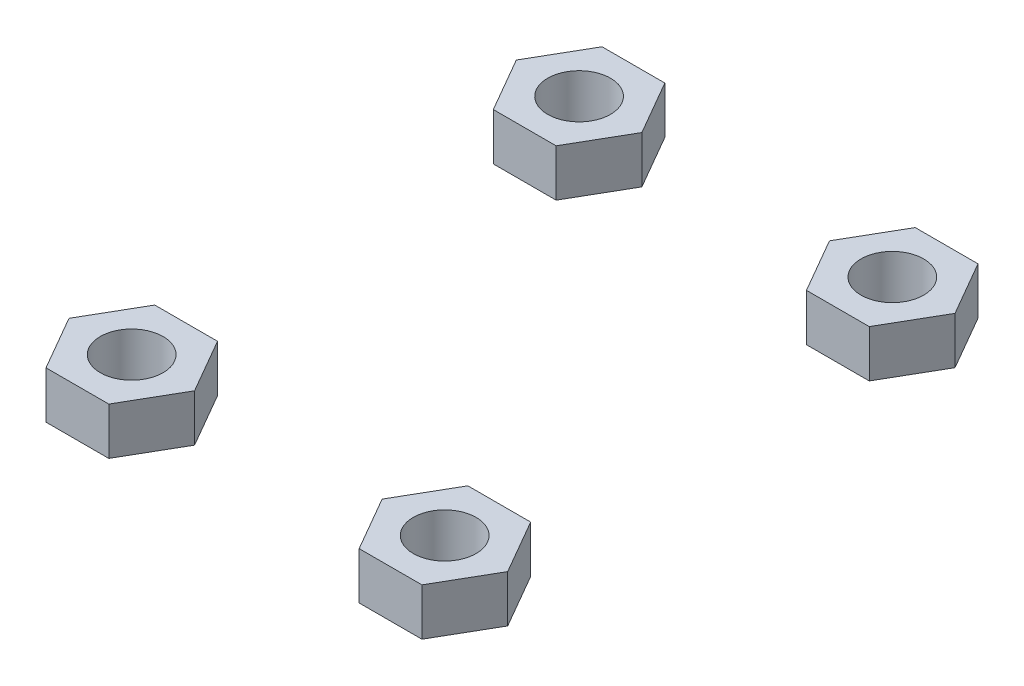
from build123d import *

# Parameters (mm, degrees)
SKETCH1_R             = 4
BOSS_EXTRUDE1_DEPTH   = 6
BOSS_EXTRUDE1_2_DEPTH = 6
BOSS_EXTRUDE1_3_DEPTH = 6
BOSS_EXTRUDE1_4_DEPTH = 6


with BuildPart() as part:
    # Sketch1 → Boss-Extrude1 (new body)
    with BuildSketch(Plane(origin=(0, 0, 0), x_dir=(1, 0, 0), z_dir=(0, 1, 0))):
        Polygon((-4, -6.92820323), (4, -6.92820323), (8, 0), (4, 6.92820323), (-4, 6.92820323), (-8, 0), align=None)
        Circle(SKETCH1_R, mode=Mode.SUBTRACT)
    extrude(amount=BOSS_EXTRUDE1_DEPTH)


with BuildPart() as body_2:
    # Sketch1 → Boss-Extrude1 2 (new body)
    with BuildSketch(Plane(origin=(0, 0, 0), x_dir=(1, 0, 0), z_dir=(0, 1, 0))):
        Polygon((31.900520373, 0), (35.900520373, 6.92820323), (43.900520373, 6.92820323), (47.900520373, 0), (43.900520373, -6.92820323), (35.900520373, -6.92820323), align=None)
        with Locations((39.900520373, 0.013548179)):
            Circle(SKETCH1_R, mode=Mode.SUBTRACT)
    extrude(amount=BOSS_EXTRUDE1_2_DEPTH)


with BuildPart() as body_3:
    # Sketch1 → Boss-Extrude1 3 (new body)
    with BuildSketch(Plane(origin=(0, 0, 0), x_dir=(1, 0, 0), z_dir=(0, 1, 0))):
        Polygon((8, -56.997084352), (4, -63.925287582), (-4, -63.925287582), (-8, -56.997084352), (-4, -50.068881122), (4, -50.068881122), align=None)
        with Locations((0, -57.010632531)):
            Circle(SKETCH1_R, mode=Mode.SUBTRACT)
    extrude(amount=BOSS_EXTRUDE1_3_DEPTH)


with BuildPart() as body_4:
    # Sketch1 → Boss-Extrude1 4 (new body)
    with BuildSketch(Plane(origin=(0, 0, 0), x_dir=(1, 0, 0), z_dir=(0, 1, 0))):
        Polygon((43.900520373, -50.068881122), (35.900520373, -50.068881122), (31.900520373, -56.997084352), (35.900520373, -63.925287582), (43.900520373, -63.925287582), (47.900520373, -56.997084352), align=None)
        with Locations((39.900520373, -57.02418071)):
            Circle(SKETCH1_R, mode=Mode.SUBTRACT)
    extrude(amount=BOSS_EXTRUDE1_4_DEPTH)


solid = Compound([part.part, body_2.part, body_3.part, body_4.part])
